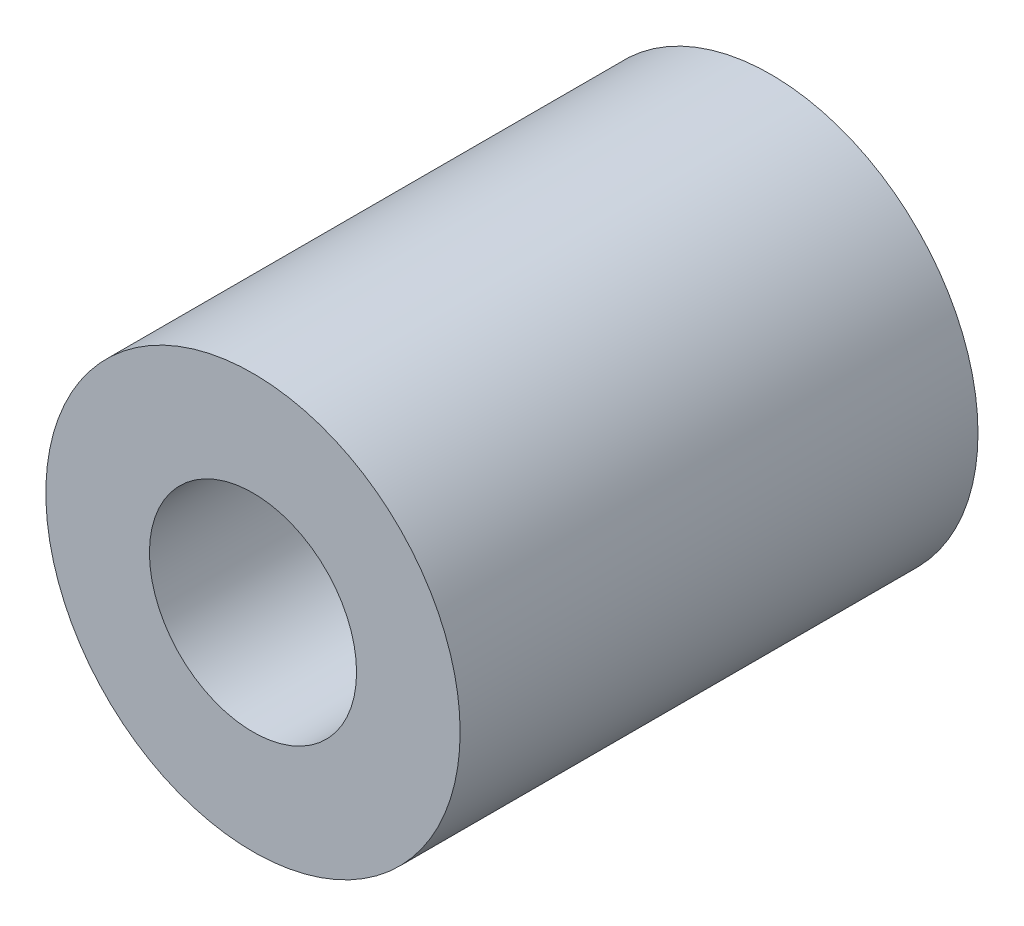
from build123d import *

# Parameters (mm, degrees)
SKETCH_1_R      = 6
EXTRUDE_1_DEPTH = 30


with BuildPart() as part:
    # Эскиз1 → Бобышка-Вытянуть1 (new body)
    with BuildSketch(Plane.XY):
        with BuildLine():
            ThreePointArc((12, 0), (0, 12), (-12, 0))
            ThreePointArc((-12, 0), (0, -12), (12, 0))
        make_face()
        Circle(SKETCH_1_R, mode=Mode.SUBTRACT)
    extrude(amount=EXTRUDE_1_DEPTH)


solid = part.part
